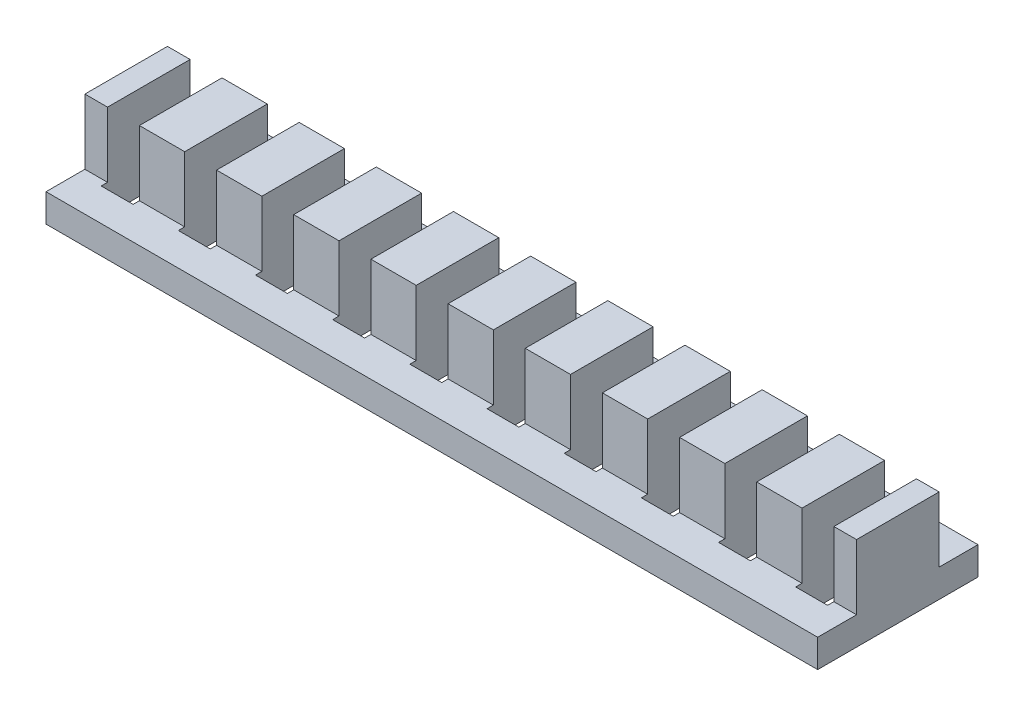
from build123d import *

# Parameters (mm, degrees)
SKETCH1_W           = 77
SKETCH1_H           = 16
BOSS_EXTRUDE1_DEPTH = 2.8
SKETCH2_W           = 77
SKETCH2_H           = 8.24
BOSS_EXTRUDE2_DEPTH = 6.5
SKETCH4_W           = 3.18
SKETCH4_H           = 9.5
CUT_EXTRUDE1_DEPTH  = 10.3


with BuildPart() as part:
    # Sketch1 → Boss-Extrude1 (new body)
    with BuildSketch(Plane(origin=(0, 0, 0), x_dir=(1, 0, 0), z_dir=(0, 1, 0))):
        Rectangle(SKETCH1_W, SKETCH1_H)
    extrude(amount=BOSS_EXTRUDE1_DEPTH)

    # Sketch2 → Boss-Extrude2 (add)
    with BuildSketch(Plane(origin=(0, 2.8, 0), x_dir=(1, 0, 0), z_dir=(0, 1, 0))):
        Rectangle(SKETCH2_W, SKETCH2_H)
    extrude(amount=BOSS_EXTRUDE2_DEPTH)

    # Sketch4 → Cut-Extrude1 (cut, through all)
    with BuildSketch(Plane.XZ):
        with Locations((-26.95, 0)):
            Rectangle(SKETCH4_W, SKETCH4_H)
        with Locations((-34.65, 0)):
            Rectangle(SKETCH4_W, SKETCH4_H)
        with Locations((-19.25, 0)):
            Rectangle(SKETCH4_W, SKETCH4_H)
        with Locations((-11.55, 0)):
            Rectangle(SKETCH4_W, SKETCH4_H)
        with Locations((-3.85, 0)):
            Rectangle(SKETCH4_W, SKETCH4_H)
        with Locations((3.85, 0)):
            Rectangle(SKETCH4_W, SKETCH4_H)
        with Locations((11.55, 0)):
            Rectangle(SKETCH4_W, SKETCH4_H)
        with Locations((19.25, 0)):
            Rectangle(SKETCH4_W, SKETCH4_H)
        with Locations((26.95, 0)):
            Rectangle(SKETCH4_W, SKETCH4_H)
        with Locations((34.65, 0)):
            Rectangle(SKETCH4_W, SKETCH4_H)
    extrude(amount=-CUT_EXTRUDE1_DEPTH, mode=Mode.SUBTRACT)


solid = part.part
